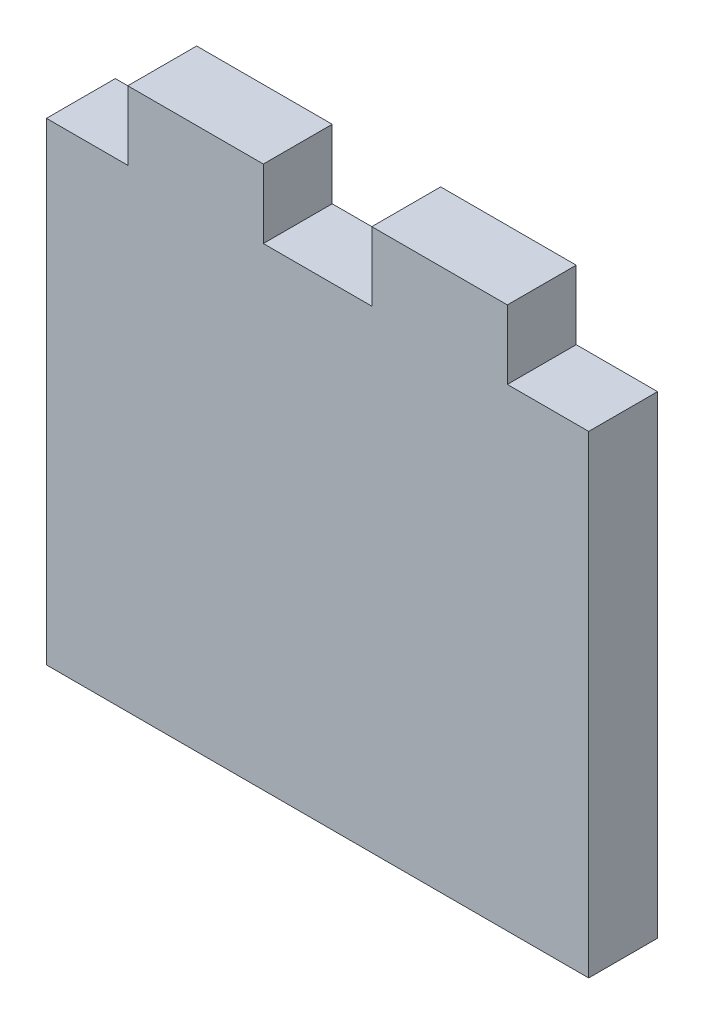
from build123d import *

# Parameters (mm, degrees)
SKETCH1_W           = 50
SKETCH1_H           = 50
BOSS_EXTRUDE1_DEPTH = 6.35
SKETCH2_W           = 7.5
SKETCH2_H           = 6.35
SKETCH2_W_2         = 10
CUT_EXTRUDE1_DEPTH  = 6.35


with BuildPart() as part:
    # Sketch1 → Boss-Extrude1 (new body)
    with BuildSketch(Plane.XY):
        with Locations((25, 25)):
            Rectangle(SKETCH1_W, SKETCH1_H)
    extrude(amount=BOSS_EXTRUDE1_DEPTH)

    # Sketch2 → Cut-Extrude1 (cut)
    with BuildSketch(Plane.XY.offset(6.35)):
        with Locations((46.25, 46.825)):
            Rectangle(SKETCH2_W, SKETCH2_H)
        with Locations((3.75, 46.825)):
            Rectangle(SKETCH2_W, SKETCH2_H)
        with Locations((25, 46.825)):
            Rectangle(SKETCH2_W_2, SKETCH2_H)
    extrude(amount=-CUT_EXTRUDE1_DEPTH, mode=Mode.SUBTRACT)


solid = part.part
